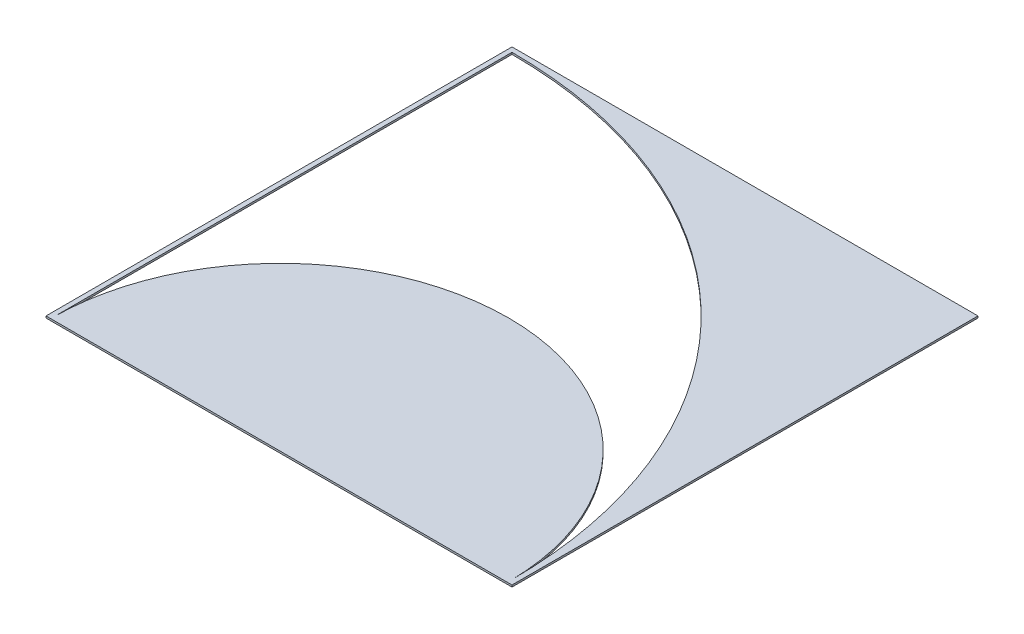
from build123d import *

# Parameters (mm, degrees)
SKIZZE1_W                       = 498
SKIZZE1_H                       = 498
AUFSATZ_LINEAR_AUSTRAGEN1_DEPTH = 2
SCHNITT_LINEAR_AUSTRAGEN2_DEPTH = 2


with BuildPart() as part:
    # Skizze1 → Aufsatz-Linear austragen1 (new body)
    with BuildSketch(Plane(origin=(0, 0, 0), x_dir=(1, 0, 0), z_dir=(0, 1, 0))):
        Rectangle(SKIZZE1_W, SKIZZE1_H)
    extrude(amount=-AUFSATZ_LINEAR_AUSTRAGEN1_DEPTH)

    # Skizze3 → Schnitt-Linear austragen2 (cut)
    with BuildSketch(Plane.XZ.offset(2)):
        with BuildLine():
            ThreePointArc((-244, 244), (0, 3.66854455), (244, 244))
            ThreePointArc((244, 244), (101.068109219, -101.068109219), (-244, -244))
            Line((-244, -244), (-244, 244))
        make_face()
    extrude(amount=-SCHNITT_LINEAR_AUSTRAGEN2_DEPTH, mode=Mode.SUBTRACT)


solid = part.part
